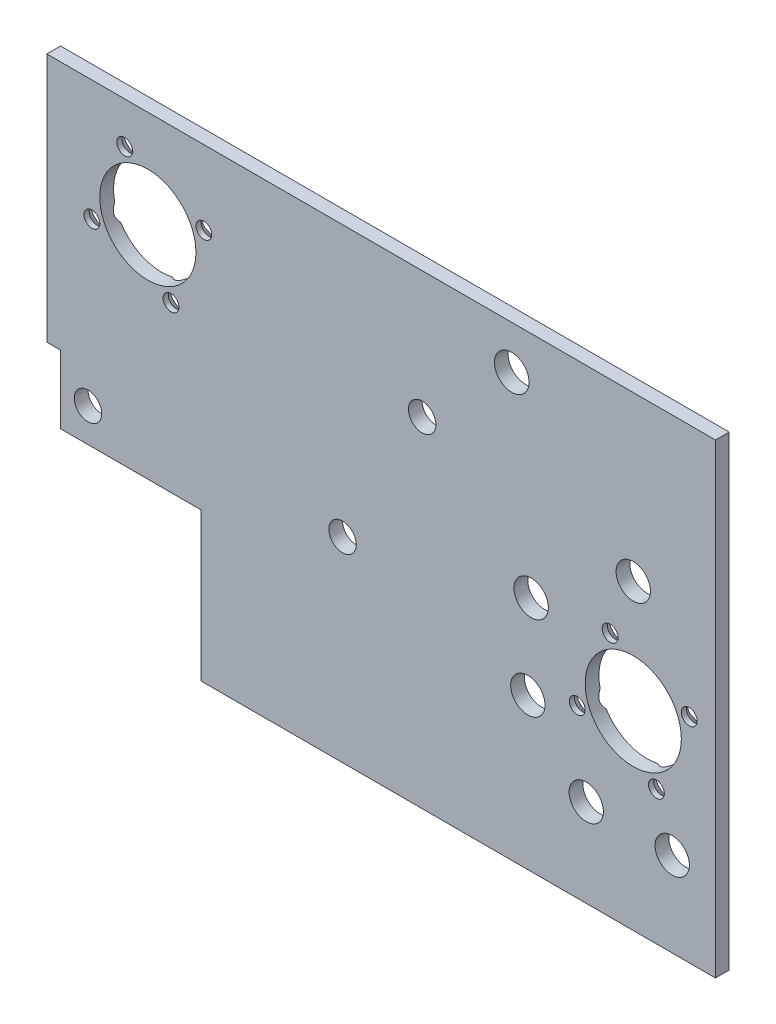
from build123d import *

# Parameters (mm, degrees)
SKETCH1_R                                      = 11.1125
SKETCH1_R_2                                    = 3.175
SKETCH1_R_3                                    = 3.96875
SKETCH1_R_4                                    = 4
BOSS_EXTRUDE1_DEPTH                            = 3.175
CSK_FOR_6_FLAT_HEAD_MACHINE_SCREW1_D           = 3.6576
CSK_FOR_6_FLAT_HEAD_MACHINE_SCREW1_DEPTH       = 8
CSK_FOR_6_FLAT_HEAD_MACHINE_SCREW1_CSINK_D     = 7.0866
CSK_FOR_6_FLAT_HEAD_MACHINE_SCREW1_CSINK_ANGLE = 82
CSK_FOR_6_FLAT_HEAD_MACHINE_SCREW1_TIP         = 1.0988539


with BuildPart() as part:
    # Sketch1 → Boss-Extrude1 (new body)
    with BuildSketch(Plane.XY):
        Polygon((-23.359070214, 22.5), (131.2, 22.5), (131.2, -85.2), (12.315929786, -85.2), (12.315929786, -50.95), (-20.184070214, -50.95), (-20.184070214, -35.2), (-23.359070214, -35.2), align=None)
        Circle(SKETCH1_R, mode=Mode.SUBTRACT)
        with Locations((112.2, -41.275)):
            Circle(SKETCH1_R, mode=Mode.SUBTRACT)
        with Locations((-13.834070214, -43.2)):
            Circle(SKETCH1_R_2, mode=Mode.SUBTRACT)
        with Locations((45, -40)):
            Circle(SKETCH1_R_2, mode=Mode.SUBTRACT)
        with Locations((63.404393546, -6.8)):
            Circle(SKETCH1_R_2, mode=Mode.SUBTRACT)
        with Locations((88.602925496, -30.405847557)):
            Circle(SKETCH1_R_3, mode=Mode.SUBTRACT)
        with Locations((112.2, -15.295)):
            Circle(SKETCH1_R_3, mode=Mode.SUBTRACT)
        with Locations((87.828697203, -50.275)):
            Circle(SKETCH1_R_3, mode=Mode.SUBTRACT)
        with Locations((101.330847557, -64.872074504)):
            Circle(SKETCH1_R_3, mode=Mode.SUBTRACT)
        with Locations((121.2, -65.646302797)):
            Circle(SKETCH1_R_3, mode=Mode.SUBTRACT)
        with Locations((84.102828318, 12.5)):
            Circle(SKETCH1_R_4, mode=Mode.SUBTRACT)
    extrude(amount=-BOSS_EXTRUDE1_DEPTH)

    # CSK for _6 Flat Head Machine Screw1
    with Locations(Plane(origin=(0, 0, -3.175), x_dir=(-1, 0, 0), z_dir=(0, 0, -1))):
        with Locations((-125.136432586, -35.922550846), (-106.847550846, -28.338567414), (-99.263567414, -46.627449154), (-117.552449154, -54.211432586), (-5.352449154, -12.936432586), (-12.936432586, 5.352449154), (5.352449154, 12.936432586), (12.936432586, -5.352449154)):
            CounterSinkHole(CSK_FOR_6_FLAT_HEAD_MACHINE_SCREW1_D / 2, CSK_FOR_6_FLAT_HEAD_MACHINE_SCREW1_CSINK_D / 2, depth=CSK_FOR_6_FLAT_HEAD_MACHINE_SCREW1_DEPTH, counter_sink_angle=CSK_FOR_6_FLAT_HEAD_MACHINE_SCREW1_CSINK_ANGLE)
            with Locations((0, 0, -(CSK_FOR_6_FLAT_HEAD_MACHINE_SCREW1_DEPTH + CSK_FOR_6_FLAT_HEAD_MACHINE_SCREW1_TIP / 2))):  # 118° drill point
                Cone(0, CSK_FOR_6_FLAT_HEAD_MACHINE_SCREW1_D / 2, CSK_FOR_6_FLAT_HEAD_MACHINE_SCREW1_TIP, mode=Mode.SUBTRACT)


solid = part.part
